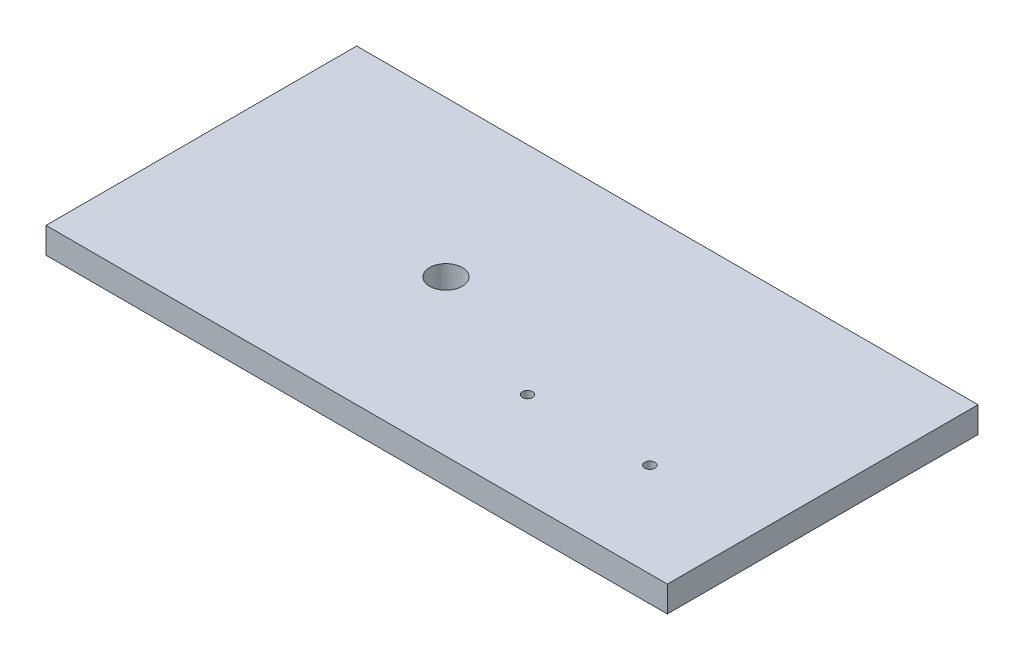
from build123d import *

# Parameters (mm, degrees)
SKETCH1_W           = 304.8
SKETCH1_H           = 152.4
BOSS_EXTRUDE1_DEPTH = 12.7
SKETCH2_R           = 8
SKETCH2_R_2         = 2.5
CUT_EXTRUDE1_DEPTH  = 13.7


with BuildPart() as part:
    # Sketch1 → Boss-Extrude1 (new body)
    with BuildSketch(Plane(origin=(0, 0, 0), x_dir=(1, 0, 0), z_dir=(0, 1, 0))):
        with Locations((152.4, -76.2)):
            Rectangle(SKETCH1_W, SKETCH1_H)
    extrude(amount=BOSS_EXTRUDE1_DEPTH)

    # Sketch2 → Cut-Extrude1 (cut, through all)
    with BuildSketch(Plane(origin=(0, 12.7, 0), x_dir=(1, 0, 0), z_dir=(0, 1, 0))):
        with Locations((120, -76.2)):
            Circle(SKETCH2_R)
        with Locations((250, -106.2)):
            Circle(SKETCH2_R_2)
        with Locations((190, -106.2)):
            Circle(SKETCH2_R_2)
    extrude(amount=-CUT_EXTRUDE1_DEPTH, mode=Mode.SUBTRACT)


solid = part.part
